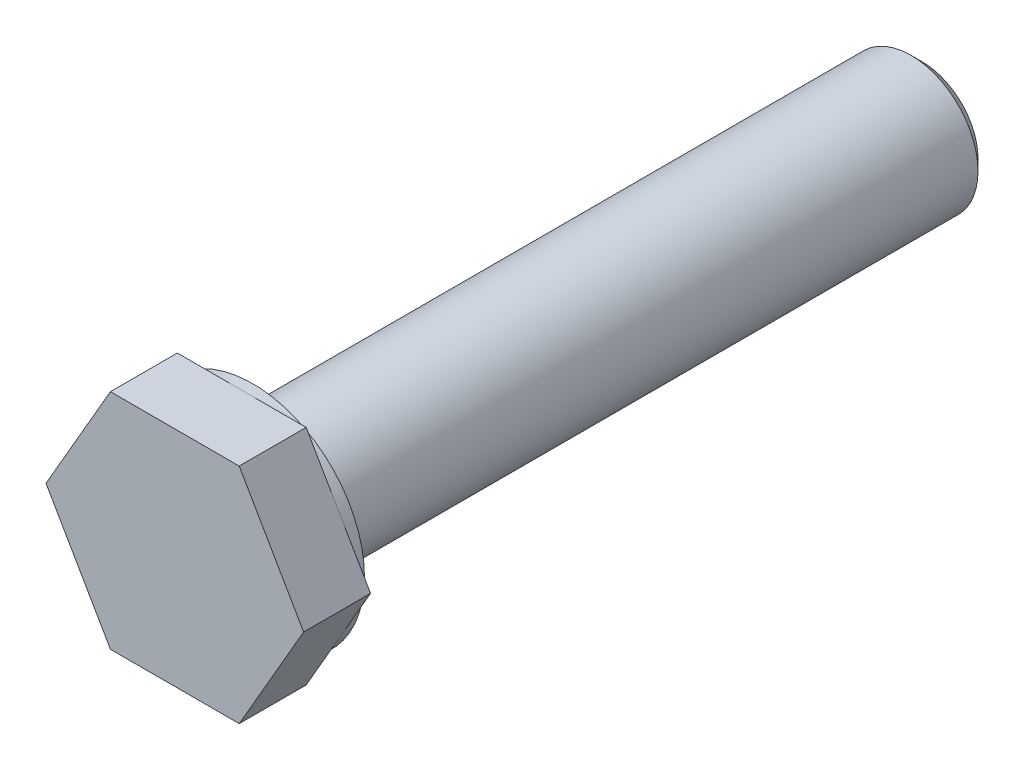
from build123d import *

# Parameters (mm, degrees)
SKETCH1_R           = 3
BOSS_EXTRUDE1_DEPTH = 30
SKETCH2_R           = 5
BOSS_EXTRUDE2_DEPTH = 0.5
BOSS_EXTRUDE3_DEPTH = 3
CHAMFER1_SIZE       = 0.5
CHAMFER2_SIZE       = 0.25


with BuildPart() as part:
    # Sketch1 → Boss-Extrude1 (new body)
    with BuildSketch(Plane.XY):
        Circle(SKETCH1_R)
    extrude(amount=BOSS_EXTRUDE1_DEPTH)

    # Sketch2 → Boss-Extrude2 (add)
    with BuildSketch(Plane.XY.offset(30)):
        Circle(SKETCH2_R)
    extrude(amount=BOSS_EXTRUDE2_DEPTH)

    # Sketch3 → Boss-Extrude3 (add)
    with BuildSketch(Plane.XY.offset(30.5)):
        Polygon((5.773502692, 0), (2.886751346, 5), (-2.886751346, 5), (-5.773502692, 0), (-2.886751346, -5), (2.886751346, -5), align=None)
    extrude(amount=BOSS_EXTRUDE3_DEPTH)

    # Chamfer1
    chamfer1_edges = [part.edges().sort_by_distance(p)[0] for p in [
        (-3, 0, 0),
    ]]
    chamfer(chamfer1_edges, length=CHAMFER1_SIZE)

    # Chamfer2
    chamfer2_edges = [part.edges().sort_by_distance(p)[0] for p in [
        (-3, 0, 30),
    ]]
    chamfer(chamfer2_edges, length=CHAMFER2_SIZE)


solid = part.part
